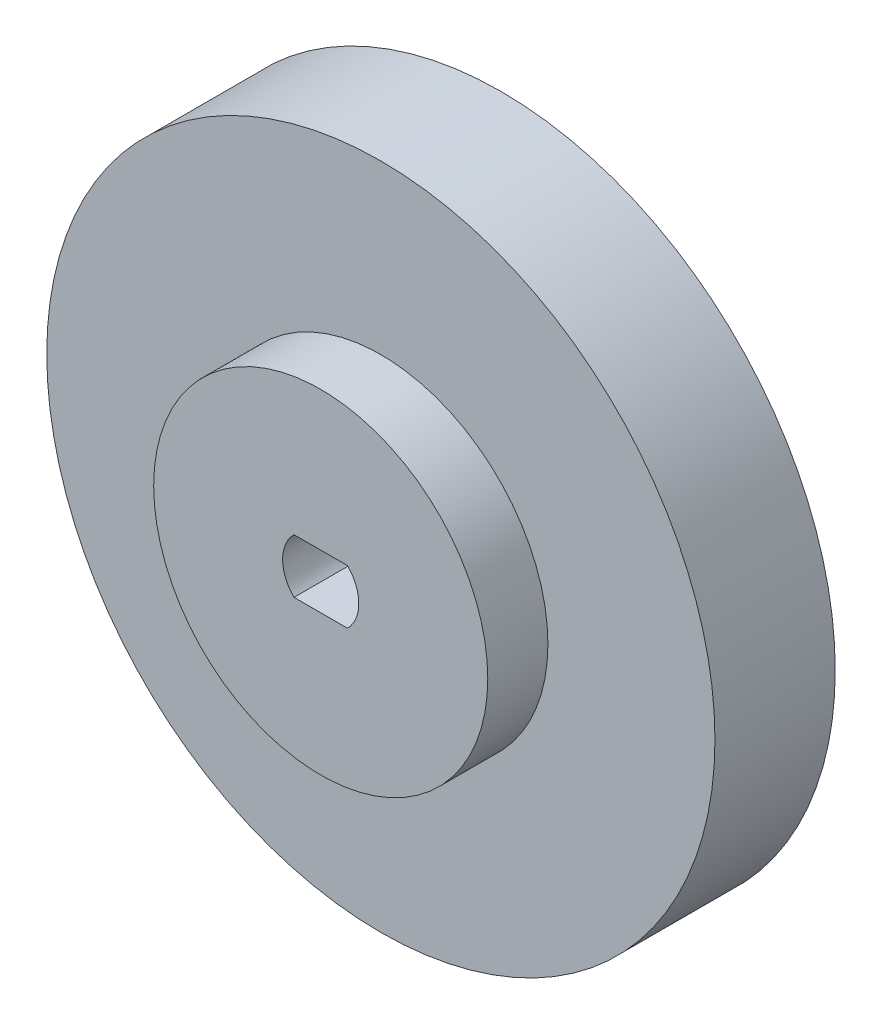
from build123d import *

# Parameters (mm, degrees)
SKETCH1_R           = 12.5
BOSS_EXTRUDE1_DEPTH = 18
BOSS_EXTRUDE2_START = -4.5
SKETCH2_R           = 25
BOSS_EXTRUDE2_DEPTH = 9
CUT_EXTRUDE1_DEPTH  = 19


with BuildPart() as part:
    # Sketch1 → Boss-Extrude1 (new body)
    with BuildSketch(Plane.XY):
        with Locations((0, -0.049046118)):
            Circle(SKETCH1_R)
    extrude(amount=BOSS_EXTRUDE1_DEPTH)

    # Sketch2 → Boss-Extrude2 (add)
    with BuildSketch(Plane.XY.offset(18).offset(BOSS_EXTRUDE2_START)):
        Circle(SKETCH2_R)
    extrude(amount=-BOSS_EXTRUDE2_DEPTH)

    # Sketch3 → Cut-Extrude1 (cut, through all)
    with BuildSketch(Plane.XY.offset(18)):
        with BuildLine():
            Line((-2, 2.03039405), (2, 2.03039405))
            ThreePointArc((2, 2.03039405), (2.85, 0), (2, -2.03039405))
            Line((2, -2.03039405), (-2, -2.03039405))
            ThreePointArc((-2, -2.03039405), (-2.85, 0), (-2, 2.03039405))
        make_face()
    extrude(amount=-CUT_EXTRUDE1_DEPTH, mode=Mode.SUBTRACT)


solid = part.part
